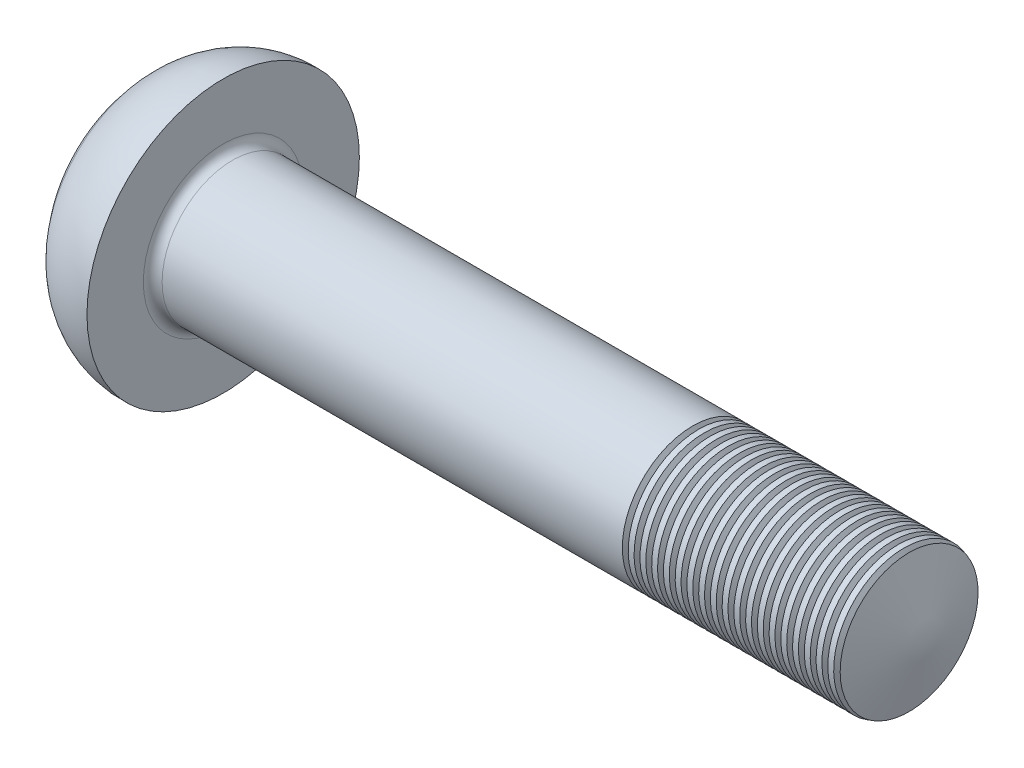
from build123d import *

# Parameters (mm, degrees)
FILLET2_R        = 0.2
LPATTERN10_COUNT = 20
LPATTERN10_PITCH = 0.25


with BuildPart() as part:
    # Sketch1 → Revolve1 (revolve)
    with BuildSketch(Plane(origin=(0, 0, 0), x_dir=(1, 0, 0), z_dir=(0, 1, 0))):
        with BuildLine():
            Line((2.37, 1.5), (17.37, 1.5))
            Line((17.37, 1.5), (17.37, 0))
            Line((17.37, 0), (0, 0))
            ThreePointArc((0, 0), (0.224879408, 1.215980768), (0.869770135, 2.271109163))
            ThreePointArc((0.869770135, 2.271109163), (1.549177667, 2.754228297), (2.37, 2.9))
            Line((2.37, 2.9), (2.37, 1.5))
        make_face()
    revolve(axis=Axis((-13.629268293, 0, 0), (1, 0, 0)))

    # Fillet2
    fillet2_edges = [part.edges().sort_by_distance(p)[0] for p in [
        (2.37, 0, 1.5),
    ]]
    fillet(fillet2_edges, radius=FILLET2_R)

    # Sketch4 → Cut-Revolve1 (revolve, cut)
    with BuildSketch(Plane(origin=(0, 0, 0), x_dir=(1, 0, 0), z_dir=(0, 1, 0))):
        Polygon((18.103454633, 0), (18.103454633, 21), (11.743066959, 21), (17.37, 0), align=None)
    revolve(axis=Axis((4.782773752, 0, 0), (1, 0, 0)), mode=Mode.SUBTRACT)

    # Sketch2 → Cut-Loft1 section 0
    with BuildSketch(Plane(origin=(0, 0, 0), x_dir=(0, 0, -1), z_dir=(1, 0, 0)), mode=Mode.PRIVATE) as cut_loft1_s0:
        Polygon((-0.4625, 0.4625), (-1.85, 0.4625), (-1.85, -0.4625), (-0.4625, -0.4625), (-0.4625, -1.85), (0.4625, -1.85), (0.4625, -0.4625), (1.85, -0.4625), (1.85, 0.4625), (0.4625, 0.4625), (0.4625, 1.85), (-0.4625, 1.85), align=None)
    loft([Vertex(2.62, 0, 0), cut_loft1_s0.sketch], mode=Mode.SUBTRACT)

    # Sketch6 → Cut-Revolve10 (revolve, cut)
    with BuildSketch(Plane.XY):
        Polygon((12.37, 1.7), (12.495, 1.7), (12.495, 1.5), (12.4325, 1.391746825), (12.37, 1.5), align=None)
    cut_revolve10 = revolve(axis=Axis((10.774329131, 0, 0), (-1, 0, 0)), mode=Mode.SUBTRACT)

    # LPattern10: Cut-Revolve10 ×20
    with Locations(*[(i * LPATTERN10_PITCH, 0, 0) for i in range(1, LPATTERN10_COUNT)]):
        add(cut_revolve10, mode=Mode.SUBTRACT)


solid = part.part
